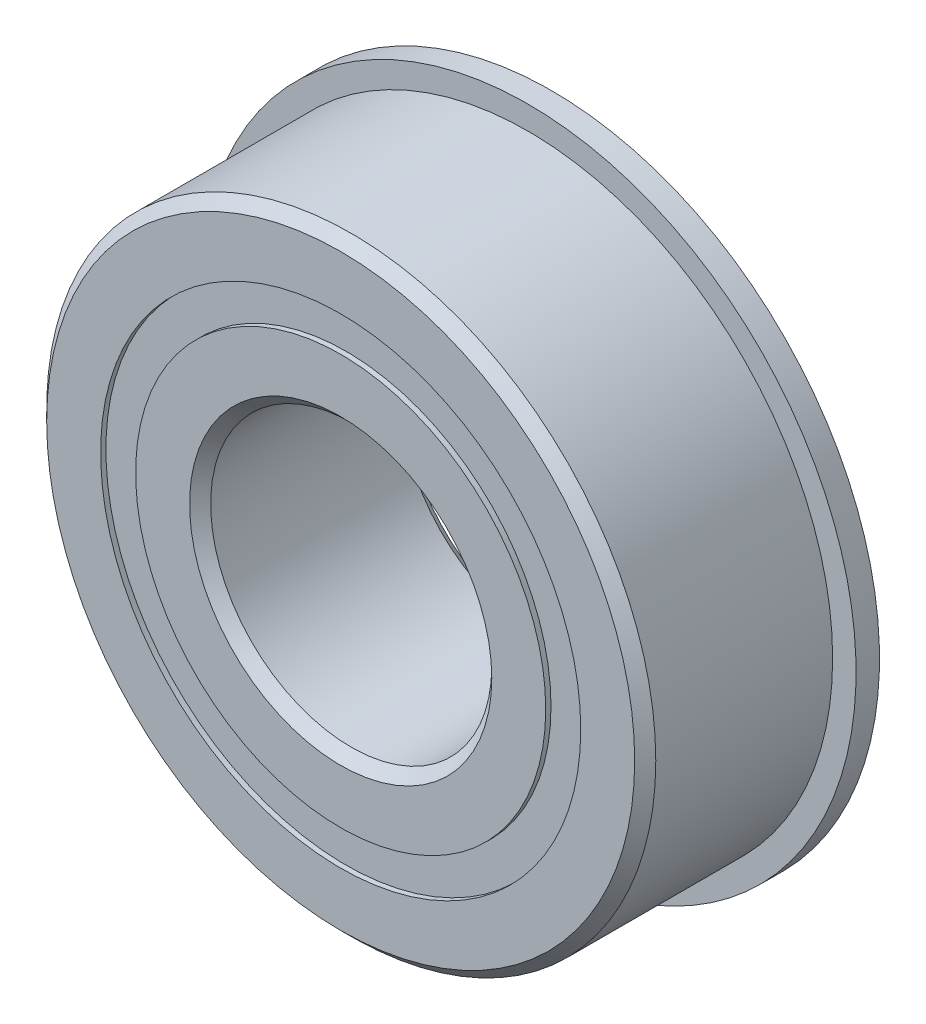
from build123d import *

# Parameters (mm, degrees)
CIRPATTERN1_COUNT = 14
SKETCH5_W         = 3.397189896
SKETCH5_H         = 2.372527472
SKETCH6_W         = 1.5875
SKETCH6_H         = 5.957486264


with BuildPart() as part:
    # Sketch1 → Revolve1 (revolve)
    with BuildSketch(Plane(origin=(0, 0, 0), x_dir=(0, 0, -1), z_dir=(1, 0, 0))):
        with BuildLine():
            Line((6.429375, 20.6375), (-6.429375, 20.6375))
            Line((-6.429375, 20.6375), (-7.14375, 19.923125))
            Line((-7.14375, 19.923125), (-7.14375, 16.267513736))
            Line((-7.14375, 16.267513736), (-3.175, 16.267513736))
            ThreePointArc((-3.175, 16.267513736), (0, 18.470622604), (3.175, 16.267513736))
            Line((3.175, 16.267513736), (7.14375, 16.267513736))
            Line((7.14375, 16.267513736), (7.14375, 19.923125))
            Line((7.14375, 19.923125), (6.429375, 20.6375))
        make_face()
    revolve(axis=Axis((0, 0, 7.14375), (0, 0, -1)))

    # Sketch6 → Revolve6 (revolve)
    with BuildSketch(Plane(origin=(0, 0, 0), x_dir=(0, 0, -1), z_dir=(1, 0, 0))):
        with Locations((6.35, 19.246256868)):
            Rectangle(SKETCH6_W, SKETCH6_H)
    revolve(axis=Axis((0, 0, -7.14375), (0, 0, 1)))


with BuildPart() as body_2:
    # Sketch3 → Revolve3 (revolve)
    with BuildSketch(Plane(origin=(0, 0, 0), x_dir=(0, 0, -1), z_dir=(1, 0, 0))):
        with BuildLine():
            Line((-7.14375, 13.894986264), (-3.175, 13.894986264))
            ThreePointArc((-3.175, 13.894986264), (0, 11.691877396), (3.175, 13.894986264))
            Line((3.175, 13.894986264), (7.14375, 13.894986264))
            Line((7.14375, 13.894986264), (7.14375, 10.239375))
            Line((7.14375, 10.239375), (6.429375, 9.525))
            Line((6.429375, 9.525), (-6.429375, 9.525))
            Line((-6.429375, 9.525), (-7.14375, 10.239375))
            Line((-7.14375, 10.239375), (-7.14375, 13.894986264))
        make_face()
    revolve(axis=Axis((0, 0, 7.14375), (0, 0, -1)))


with BuildPart() as body_3:
    # Sketch4 → Revolve4 (revolve)
    with BuildSketch(Plane(origin=(0, 0, 0), x_dir=(0, 0, -1), z_dir=(1, 0, 0))):
        with BuildLine():
            Line((-3.389372604, 15.08125), (3.389372604, 15.08125))
            ThreePointArc((3.389372604, 15.08125), (0, 18.470622604), (-3.389372604, 15.08125))
        make_face()
    revolve(axis=Axis((0, 15.08125, 3.389372604), (0, 0, -1)))


with BuildPart() as cirpattern1_1:
    # CirPattern1: pattern copy
    add(body_3.part.rotate(Axis((0, 0, -7.14375), (0, 0, 1)), 1 * 360 / CIRPATTERN1_COUNT))


with BuildPart() as cirpattern1_2:
    # CirPattern1: pattern copy
    add(body_3.part.rotate(Axis((0, 0, -7.14375), (0, 0, 1)), 2 * 360 / CIRPATTERN1_COUNT))


with BuildPart() as cirpattern1_3:
    # CirPattern1: pattern copy
    add(body_3.part.rotate(Axis((0, 0, -7.14375), (0, 0, 1)), 3 * 360 / CIRPATTERN1_COUNT))


with BuildPart() as cirpattern1_4:
    # CirPattern1: pattern copy
    add(body_3.part.rotate(Axis((0, 0, -7.14375), (0, 0, 1)), 4 * 360 / CIRPATTERN1_COUNT))


with BuildPart() as cirpattern1_5:
    # CirPattern1: pattern copy
    add(body_3.part.rotate(Axis((0, 0, -7.14375), (0, 0, 1)), 5 * 360 / CIRPATTERN1_COUNT))


with BuildPart() as cirpattern1_6:
    # CirPattern1: pattern copy
    add(body_3.part.rotate(Axis((0, 0, -7.14375), (0, 0, 1)), 6 * 360 / CIRPATTERN1_COUNT))


with BuildPart() as cirpattern1_7:
    # CirPattern1: pattern copy
    add(body_3.part.rotate(Axis((0, 0, -7.14375), (0, 0, 1)), 7 * 360 / CIRPATTERN1_COUNT))


with BuildPart() as cirpattern1_8:
    # CirPattern1: pattern copy
    add(body_3.part.rotate(Axis((0, 0, -7.14375), (0, 0, 1)), 8 * 360 / CIRPATTERN1_COUNT))


with BuildPart() as cirpattern1_9:
    # CirPattern1: pattern copy
    add(body_3.part.rotate(Axis((0, 0, -7.14375), (0, 0, 1)), 9 * 360 / CIRPATTERN1_COUNT))


with BuildPart() as cirpattern1_10:
    # CirPattern1: pattern copy
    add(body_3.part.rotate(Axis((0, 0, -7.14375), (0, 0, 1)), 10 * 360 / CIRPATTERN1_COUNT))


with BuildPart() as cirpattern1_11:
    # CirPattern1: pattern copy
    add(body_3.part.rotate(Axis((0, 0, -7.14375), (0, 0, 1)), 11 * 360 / CIRPATTERN1_COUNT))


with BuildPart() as cirpattern1_12:
    # CirPattern1: pattern copy
    add(body_3.part.rotate(Axis((0, 0, -7.14375), (0, 0, 1)), 12 * 360 / CIRPATTERN1_COUNT))


with BuildPart() as cirpattern1_13:
    # CirPattern1: pattern copy
    add(body_3.part.rotate(Axis((0, 0, -7.14375), (0, 0, 1)), 13 * 360 / CIRPATTERN1_COUNT))


with BuildPart() as body_17:
    # Sketch5 → Revolve5 (revolve)
    with BuildSketch(Plane(origin=(0, 0, 0), x_dir=(0, 0, -1), z_dir=(1, 0, 0))):
        with Locations((-5.087967552, 15.08125)):
            Rectangle(SKETCH5_W, SKETCH5_H)
        with Locations((5.087967552, 15.08125)):
            Rectangle(SKETCH5_W, SKETCH5_H)
    revolve(axis=Axis((0, 0, 7.14375), (0, 0, -1)))


solid = Compound([part.part, body_2.part, body_3.part, cirpattern1_1.part, cirpattern1_2.part, cirpattern1_3.part, cirpattern1_4.part, cirpattern1_5.part, cirpattern1_6.part, cirpattern1_7.part, cirpattern1_8.part, cirpattern1_9.part, cirpattern1_10.part, cirpattern1_11.part, cirpattern1_12.part, cirpattern1_13.part, body_17.part])
